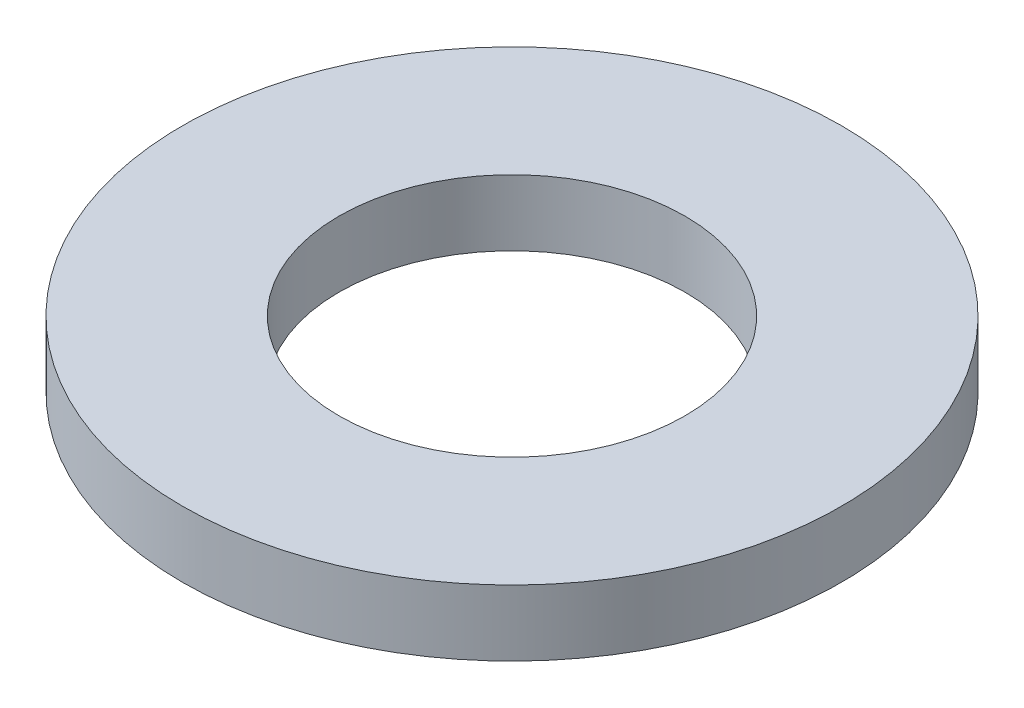
from build123d import *

# Parameters (mm, degrees)
SKETCH1_R      = 10
SKETCH1_R_2    = 5.25
EXTRUDE1_DEPTH = 2


with BuildPart() as part:
    # Sketch1 → Extrude1 (new body)
    with BuildSketch(Plane(origin=(0, 0, 0), x_dir=(1, 0, 0), z_dir=(0, 1, 0))):
        with Locations(Location((0, 0, 0), (0, 0, 270))):  # turned: the seam where the file's is
            Circle(SKETCH1_R)
        with Locations(Location((0, 0, 0), (0, 0, 270))):  # turned: the seam where the file's is
            Circle(SKETCH1_R_2, mode=Mode.SUBTRACT)
    extrude(amount=EXTRUDE1_DEPTH)


solid = part.part
